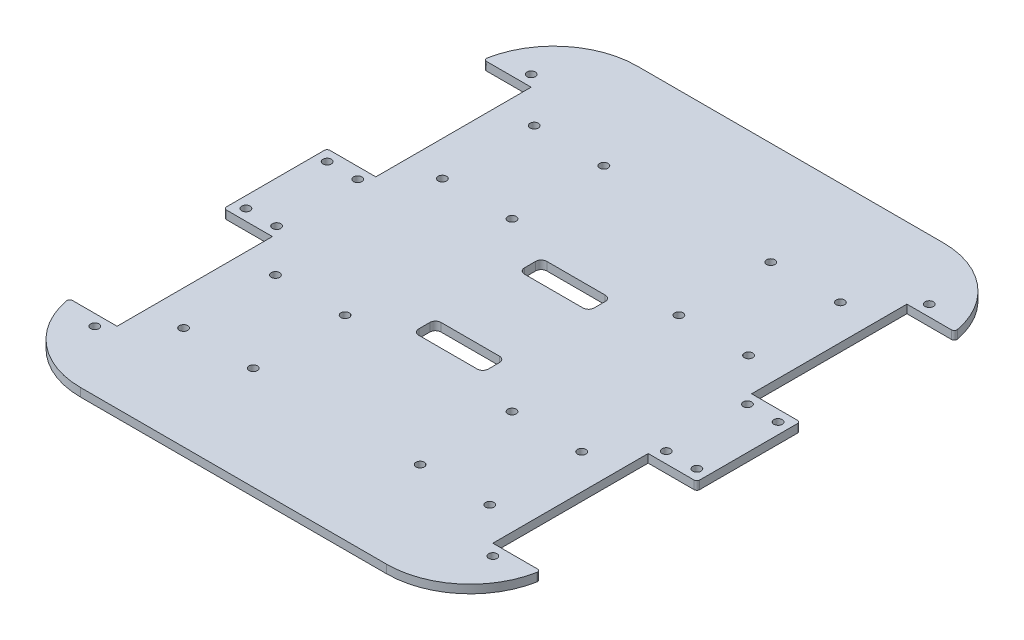
from build123d import *

# Parameters (mm, degrees)
SKETCH1_W           = 170
SKETCH1_H           = 200
BOSS_EXTRUDE1_DEPTH = 3
SKETCH2_R           = 1.5
CUT_EXTRUDE1_DEPTH  = 43
FILLET1_R           = 30
SKETCH4_W           = 29.4
SKETCH4_H           = 55.8
CUT_EXTRUDE4_DEPTH  = 10
FILLET3_R           = 1
FILLET4_R           = 1
FILLET5_R           = 1
FILLET6_R           = 1
FILLET7_R           = 1
FILLET8_R           = 1
FILLET9_R           = 1
FILLET10_R          = 1
SKETCH5_W           = 25
SKETCH5_H           = 8
CUT_EXTRUDE5_DEPTH  = 10
FILLET11_R          = 2
FILLET12_R          = 2
FILLET13_R          = 2
FILLET14_R          = 2
FILLET15_R          = 2
FILLET16_R          = 2
SKETCH6_R           = 1.5
CUT_EXTRUDE6_DEPTH  = 10
SKETCH7_R           = 1.5
CUT_EXTRUDE8_DEPTH  = 10


with BuildPart() as part:
    # Sketch1 → Boss-Extrude1 (new body)
    with BuildSketch(Plane(origin=(0, 0, 0), x_dir=(1, 0, 0), z_dir=(0, 1, 0))):
        Rectangle(SKETCH1_W, SKETCH1_H)
    extrude(amount=BOSS_EXTRUDE1_DEPTH)

    # Sketch2 → Cut-Extrude1 (cut)
    with BuildSketch(Plane.XZ):
        with Locations((-55, 62.98)):
            Circle(SKETCH2_R)
        with Locations((-55, 29.98)):
            Circle(SKETCH2_R)
        with Locations((-29.98, 62.98)):
            Circle(SKETCH2_R)
        with Locations((-29.98, 29.98)):
            Circle(SKETCH2_R)
        with Locations((29.98, 62.98)):
            Circle(SKETCH2_R)
        with Locations((55, 62.98)):
            Circle(SKETCH2_R)
        with Locations((55, 29.98)):
            Circle(SKETCH2_R)
        with Locations((29.98, 29.98)):
            Circle(SKETCH2_R)
        with Locations((29.98, -62.98)):
            Circle(SKETCH2_R)
        with Locations((29.98, -29.98)):
            Circle(SKETCH2_R)
        with Locations((55, -62.98)):
            Circle(SKETCH2_R)
        with Locations((55, -29.98)):
            Circle(SKETCH2_R)
        with Locations((-29.98, -62.98)):
            Circle(SKETCH2_R)
        with Locations((-55, -62.98)):
            Circle(SKETCH2_R)
        with Locations((-55, -29.98)):
            Circle(SKETCH2_R)
        with Locations((-29.98, -29.98)):
            Circle(SKETCH2_R)
    extrude(amount=-CUT_EXTRUDE1_DEPTH, mode=Mode.SUBTRACT)

    # Fillet1
    fillet1_edges = [part.edges().sort_by_distance(p)[0] for p in [
        (85, 1.5, 100),
        (-85, 1.5, 100),
        (-85, 1.5, -100),
        (85, 1.5, -100),
    ]]
    fillet(fillet1_edges, radius=FILLET1_R)

    # Sketch4 → Cut-Extrude4 (cut)
    with BuildSketch(Plane.XZ):
        with Locations((-82.2, 46.48)):
            Rectangle(SKETCH4_W, SKETCH4_H)
        with Locations((82.2, 46.48)):
            Rectangle(SKETCH4_W, SKETCH4_H)
        with Locations((82.2, -46.48)):
            Rectangle(SKETCH4_W, SKETCH4_H)
        with Locations((-82.2, -46.48)):
            Rectangle(SKETCH4_W, SKETCH4_H)
    extrude(amount=-CUT_EXTRUDE4_DEPTH, mode=Mode.SUBTRACT)

    # Fillet3
    fillet3_edges = [part.edges().sort_by_distance(p)[0] for p in [
        (-84.6785377, 1.5, 74.38),
    ]]
    fillet(fillet3_edges, radius=FILLET3_R)

    # Fillet4
    fillet4_edges = [part.edges().sort_by_distance(p)[0] for p in [
        (-85, 1.5, 18.58),
    ]]
    fillet(fillet4_edges, radius=FILLET4_R)

    # Fillet5
    fillet5_edges = [part.edges().sort_by_distance(p)[0] for p in [
        (84.6785377, 1.5, 74.38),
    ]]
    fillet(fillet5_edges, radius=FILLET5_R)

    # Fillet6
    fillet6_edges = [part.edges().sort_by_distance(p)[0] for p in [
        (85, 1.5, 18.58),
    ]]
    fillet(fillet6_edges, radius=FILLET6_R)

    # Fillet7
    fillet7_edges = [part.edges().sort_by_distance(p)[0] for p in [
        (85, 1.5, -18.58),
    ]]
    fillet(fillet7_edges, radius=FILLET7_R)

    # Fillet8
    fillet8_edges = [part.edges().sort_by_distance(p)[0] for p in [
        (84.6785377, 1.5, -74.38),
    ]]
    fillet(fillet8_edges, radius=FILLET8_R)

    # Fillet9
    fillet9_edges = [part.edges().sort_by_distance(p)[0] for p in [
        (-84.6785377, 1.5, -74.38),
    ]]
    fillet(fillet9_edges, radius=FILLET9_R)

    # Fillet10
    fillet10_edges = [part.edges().sort_by_distance(p)[0] for p in [
        (-85, 1.5, -18.58),
    ]]
    fillet(fillet10_edges, radius=FILLET10_R)

    # Sketch5 → Cut-Extrude5 (cut)
    with BuildSketch(Plane.XZ):
        with Locations((0, -19)):
            Rectangle(SKETCH5_W, SKETCH5_H)
        with Locations((0, 19)):
            Rectangle(SKETCH5_W, SKETCH5_H)
    extrude(amount=-CUT_EXTRUDE5_DEPTH, mode=Mode.SUBTRACT)

    # Fillet11
    fillet11_edges = [part.edges().sort_by_distance(p)[0] for p in [
        (-12.5, 1.5, -23),
        (-12.5, 1.5, -15),
        (12.5, 1.5, -15),
    ]]
    fillet(fillet11_edges, radius=FILLET11_R)

    # Fillet12
    fillet12_edges = [part.edges().sort_by_distance(p)[0] for p in [
        (12.5, 1.5, -23),
    ]]
    fillet(fillet12_edges, radius=FILLET12_R)

    # Fillet13
    fillet13_edges = [part.edges().sort_by_distance(p)[0] for p in [
        (12.5, 1.5, 15),
    ]]
    fillet(fillet13_edges, radius=FILLET13_R)

    # Fillet14
    fillet14_edges = [part.edges().sort_by_distance(p)[0] for p in [
        (12.5, 1.5, 23),
    ]]
    fillet(fillet14_edges, radius=FILLET14_R)

    # Fillet15
    fillet15_edges = [part.edges().sort_by_distance(p)[0] for p in [
        (-12.5, 1.5, 23),
    ]]
    fillet(fillet15_edges, radius=FILLET15_R)

    # Fillet16
    fillet16_edges = [part.edges().sort_by_distance(p)[0] for p in [
        (-12.5, 1.5, 15),
    ]]
    fillet(fillet16_edges, radius=FILLET16_R)

    # Sketch6 → Cut-Extrude6 (cut)
    with BuildSketch(Plane.XZ):
        with Locations((-81, -14.58)):
            Circle(SKETCH6_R)
        with Locations((-81, 14.58)):
            Circle(SKETCH6_R)
        with Locations((-70, 14.58)):
            Circle(SKETCH6_R)
        with Locations((-70, -14.58)):
            Circle(SKETCH6_R)
        with Locations((70, -14.58)):
            Circle(SKETCH6_R)
        with Locations((70, 14.58)):
            Circle(SKETCH6_R)
        with Locations((81, 14.58)):
            Circle(SKETCH6_R)
        with Locations((81, -14.58)):
            Circle(SKETCH6_R)
    extrude(amount=-CUT_EXTRUDE6_DEPTH, mode=Mode.SUBTRACT)

    # Sketch7 → Cut-Extrude8 (cut)
    with BuildSketch(Plane.XZ):
        with Locations((-71.5, 78.38)):
            Circle(SKETCH7_R)
        with Locations((71.5, 78.38)):
            Circle(SKETCH7_R)
        with Locations((71.5, -78.38)):
            Circle(SKETCH7_R)
        with Locations((-71.5, -78.38)):
            Circle(SKETCH7_R)
    extrude(amount=-CUT_EXTRUDE8_DEPTH, mode=Mode.SUBTRACT)


solid = part.part
